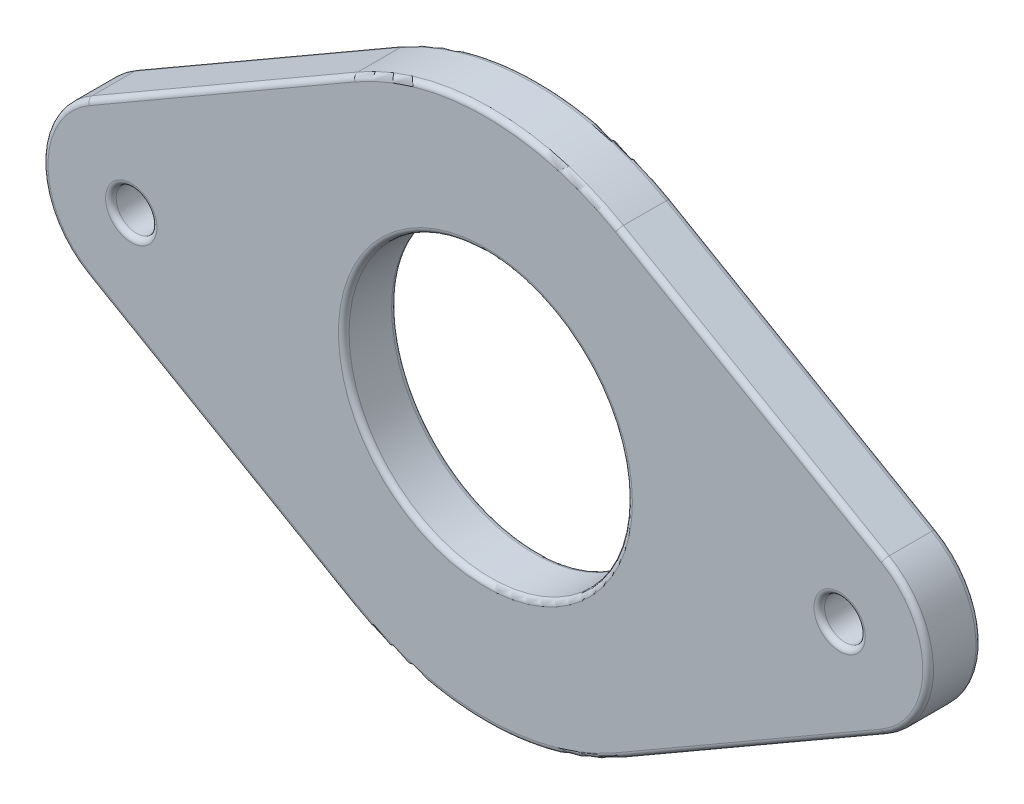
from build123d import *

# Parameters (mm, degrees)
SKETCH1_R           = 1.15
SKETCH1_R_2         = 8
BOSS_EXTRUDE1_DEPTH = 3
FILLET1_R           = 0.3


with BuildPart() as part:
    # Sketch1 → Boss-Extrude1 (new body)
    with BuildSketch(Plane.XY):
        with BuildLine():
            Line((-22.5, 4.330127019), (-7.5, 12.990381057))
            ThreePointArc((-7.5, 12.990381057), (0, 15), (7.5, 12.990381057))
            Line((7.5, 12.990381057), (22.5, 4.330127019))
            ThreePointArc((22.5, 4.330127019), (25, 0), (22.5, -4.330127019))
            Line((22.5, -4.330127019), (7.5, -12.990381057))
            ThreePointArc((7.5, -12.990381057), (0, -15), (-7.5, -12.990381057))
            Line((-7.5, -12.990381057), (-22.5, -4.330127019))
            ThreePointArc((-22.5, -4.330127019), (-25, 0), (-22.5, 4.330127019))
        make_face()
        with Locations((-20, 0)):
            Circle(SKETCH1_R, mode=Mode.SUBTRACT)
        with Locations((20, 0)):
            Circle(SKETCH1_R, mode=Mode.SUBTRACT)
        Circle(SKETCH1_R_2, mode=Mode.SUBTRACT)
    extrude(amount=BOSS_EXTRUDE1_DEPTH)

    # Fillet1
    fillet1_edges = [part.edges().sort_by_distance(p)[0] for p in [
        (15, -8.660254038, 0),
        (0, -15, 0),
        (-15, -8.660254038, 0),
        (-25, 0, 0),
        (0, -15, 3),
        (15, -8.660254038, 3),
        (25, 0, 3),
        (-8, 0, 0),
        (-8, 0, 3),
        (15, 8.660254038, 3),
        (-21.15, 0, 0),
        (-21.15, 0, 3),
        (0, 15, 3),
        (18.85, 0, 0),
        (18.85, 0, 3),
        (-15, 8.660254038, 3),
        (-25, 0, 3),
        (-15, 8.660254038, 0),
        (-15, -8.660254038, 3),
        (0, 15, 0),
        (15, 8.660254038, 0),
        (25, 0, 0),
    ]]
    fillet(fillet1_edges, radius=FILLET1_R)


solid = part.part
